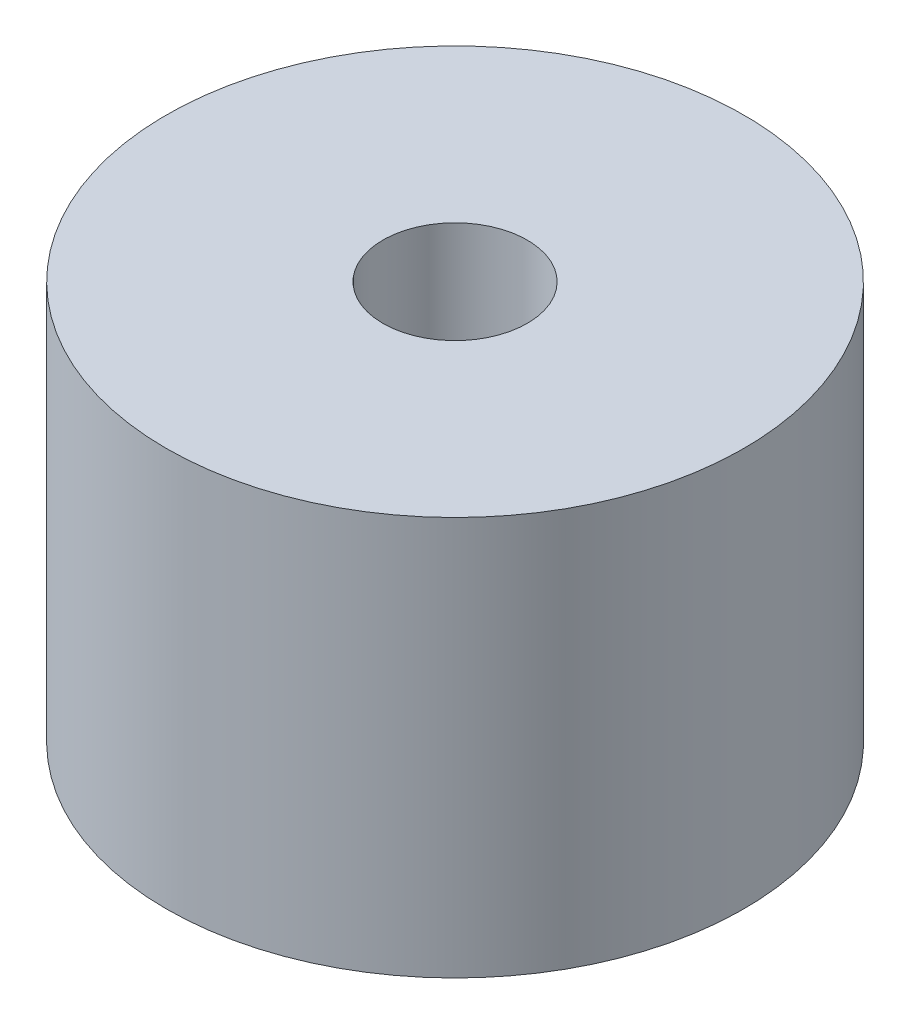
from build123d import *

# Parameters (mm, degrees)
SKETCH1_R             = 4.2
BOSS_EXTRUDE1_DEPTH   = 2.9
M3X0_5_TAPPED_HOLE1_D = 2.1


with BuildPart() as part:
    # Sketch1 → Boss-Extrude1 (new body, symmetric)
    with BuildSketch(Plane(origin=(0, 0, 0), x_dir=(1, 0, 0), z_dir=(0, 1, 0))):
        Circle(SKETCH1_R)
    extrude(amount=BOSS_EXTRUDE1_DEPTH, both=True)

    # M3x0.5 Tapped Hole1 (through all)
    with Locations(Plane(origin=(0, 2.9, 0), x_dir=(1, 0, 0), z_dir=(0, 1, 0))):
        with Locations((0, 0)):
            Hole(M3X0_5_TAPPED_HOLE1_D / 2)


solid = part.part
